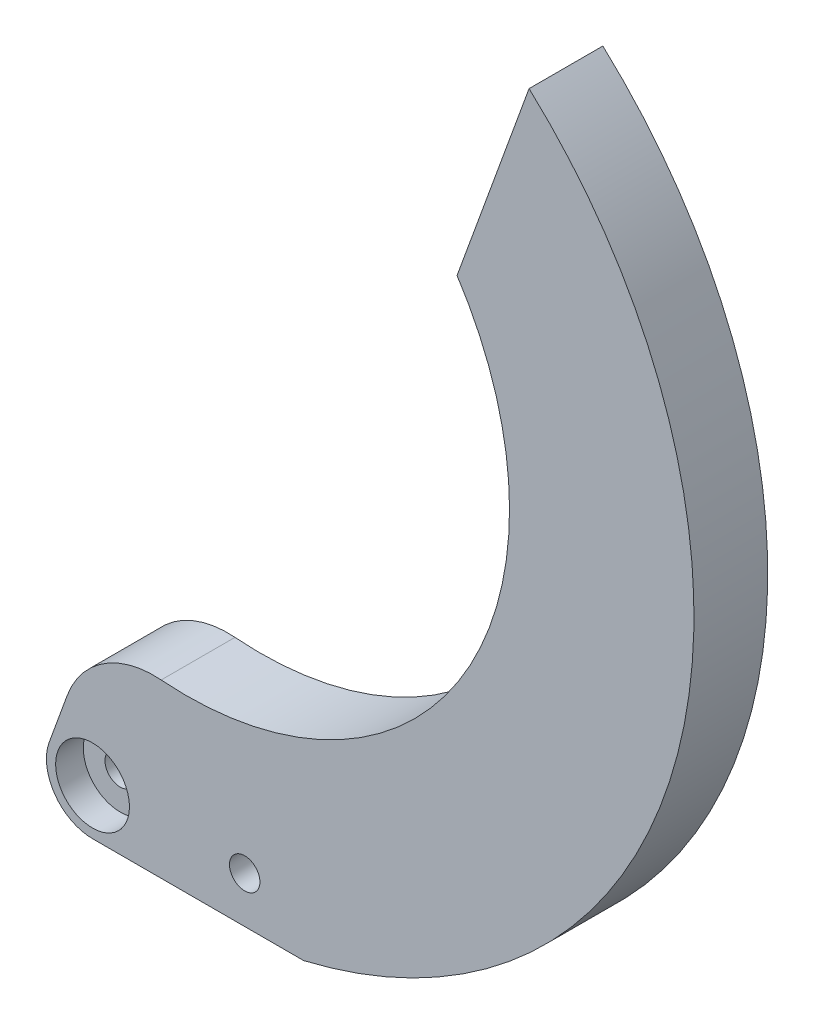
from build123d import *

# Parameters (mm, degrees)
SKETCH_1_R          = 1.65
EXTRUDE_1_DEPTH     = 8
FILLET_1_R          = 10
SKETCH_2_R          = 4
CUT_EXTRUDE_1_DEPTH = 3


with BuildPart() as part:
    # 草圖1 → 填料-伸長1 (new body)
    with BuildSketch(Plane.XY):
        with BuildLine():
            Line((0, -5), (22.896270517, -5))
            ThreePointArc((22.896270517, -5), (63.449308727, 34.693340668), (47.334627368, 89.103149031))
            Line((47.334627368, 89.103149031), (39.525260877, 67.647090937))
            ThreePointArc((39.525260877, 67.647090937), (38.24035653, 27.551768918), (0.138664652, 15))
            Line((0.138664652, 15), (-4.698463104, 1.710100717))
            ThreePointArc((-4.698463104, 1.710100717), (-4.095760221, -2.867882182), (0, -5))
        make_face()
        Circle(SKETCH_1_R, mode=Mode.SUBTRACT)
        with Locations((16.5, 0)):
            Circle(SKETCH_1_R, mode=Mode.SUBTRACT)
    extrude(amount=EXTRUDE_1_DEPTH)

    # 圓角1
    fillet_1_edges = [part.edges().sort_by_distance(p)[0] for p in [
        (0.138664652, 15, 4),
    ]]
    fillet(fillet_1_edges, radius=FILLET_1_R)

    # 草圖2 → 除料-伸長1 (cut)
    with BuildSketch(Plane(origin=(0, 0, 8), x_dir=(-1, 0, 0), z_dir=(0, 0, -1))):
        Circle(SKETCH_2_R)
    extrude(amount=CUT_EXTRUDE_1_DEPTH, mode=Mode.SUBTRACT)


solid = part.part
